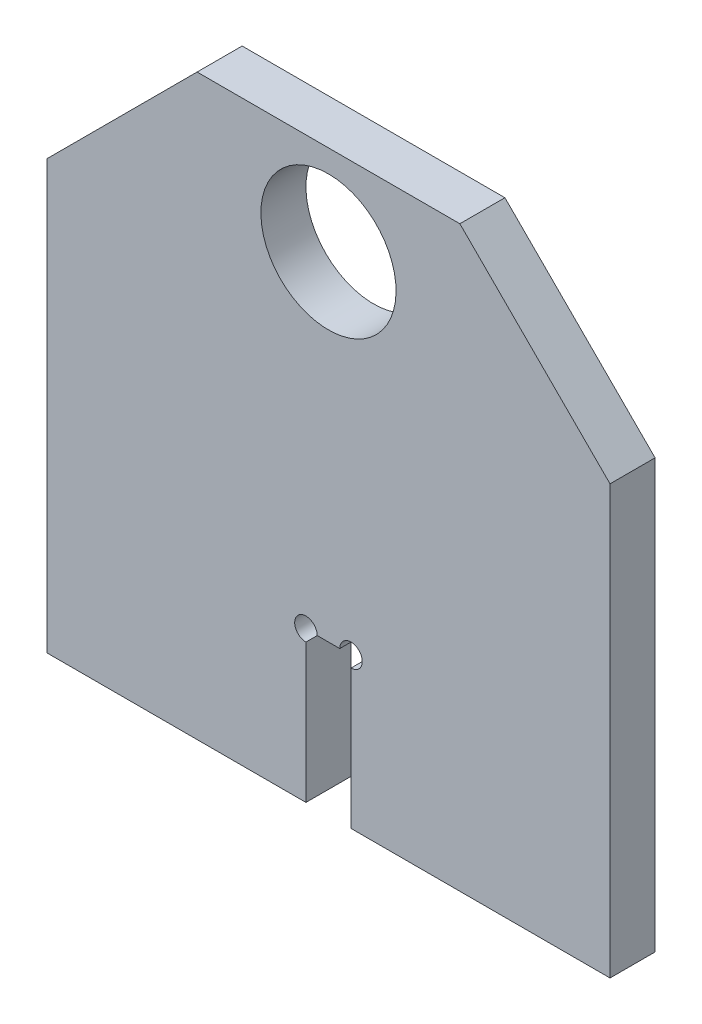
from build123d import *

# Parameters (mm, degrees)
SKETCH1_R           = 9
BOSS_EXTRUDE1_DEPTH = 6


with BuildPart() as part:
    # Sketch1 → Boss-Extrude1 (new body)
    with BuildSketch(Plane.XY):
        with BuildLine():
            Line((3, 100), (37.5, 100))
            Line((37.5, 100), (37.5, 157))
            Line((37.5, 157), (17.5, 177))
            Line((17.5, 177), (-17.5, 177))
            Line((-17.5, 177), (-37.5, 157))
            Line((-37.5, 157), (-37.5, 100))
            Line((-37.5, 100), (-3, 100))
            Line((-3, 100), (-3, 118.5))
            ThreePointArc((-3, 118.5), (-4.060660172, 121.060660172), (-1.5, 120))
            Line((-1.5, 120), (1.5, 120))
            ThreePointArc((1.5, 120), (3, 121.5), (4.5, 120))
            ThreePointArc((4.5, 120), (4.060660172, 118.939339828), (3, 118.5))
            Line((3, 118.5), (3, 100))
        make_face()
        with Locations((8.6489e-05, 165)):
            Circle(SKETCH1_R, mode=Mode.SUBTRACT)
    extrude(amount=BOSS_EXTRUDE1_DEPTH)


solid = part.part
